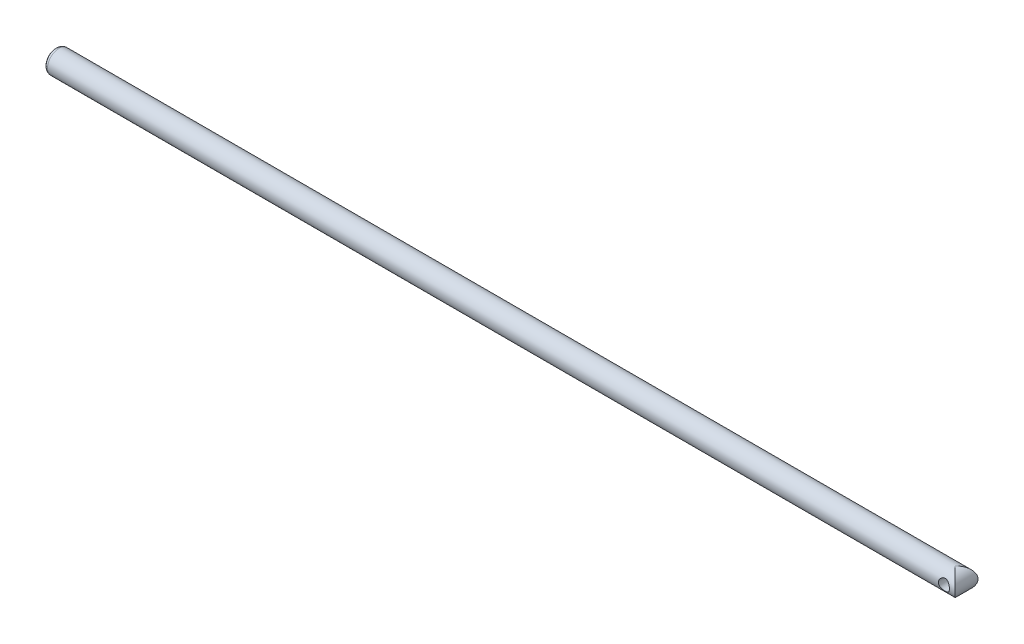
from build123d import *

# Parameters (mm, degrees)
SKETCH1_R               = 2.25
BOSS_EXTRUDE1_DEPTH     = 180
FILLET1_R               = 0.75
SKETCH2_R               = 1.1
CUT_EXTRUDE1_DEPTH      = 3.25
CUT_EXTRUDE1_DEPTH_BACK = 3.25


with BuildPart() as part:
    # Sketch1 → Boss-Extrude1 (new body)
    with BuildSketch(Plane(origin=(0, 0, 0), x_dir=(0, 0, -1), z_dir=(1, 0, 0))):
        Circle(SKETCH1_R)
    extrude(amount=BOSS_EXTRUDE1_DEPTH)

    # Fillet1
    fillet1_edges = [part.edges().sort_by_distance(p)[0] for p in [
        (0, 0, 2.25),
    ]]
    fillet(fillet1_edges, radius=FILLET1_R)

    # Sketch2 → Cut-Extrude1 (cut, two sides)
    with BuildSketch(Plane.XY) as cut_extrude1_sk:
        with BuildLine():
            Line((180, 2.25), (177.75, 2.25))
            ThreePointArc((177.75, 2.25), (179.340990258, 1.590990258), (180, 0))
            Line((180, 0), (180, 2.25))
        make_face()
        with BuildLine():
            Line((180, -2.25), (180, 0))
            ThreePointArc((180, 0), (179.340990258, -1.590990258), (177.75, -2.25))
            Line((177.75, -2.25), (180, -2.25))
        make_face()
        with Locations((177.75, 0)):
            Circle(SKETCH2_R)
    extrude(amount=CUT_EXTRUDE1_DEPTH, mode=Mode.SUBTRACT)
    extrude(cut_extrude1_sk.sketch, amount=-CUT_EXTRUDE1_DEPTH_BACK, mode=Mode.SUBTRACT)


solid = part.part
